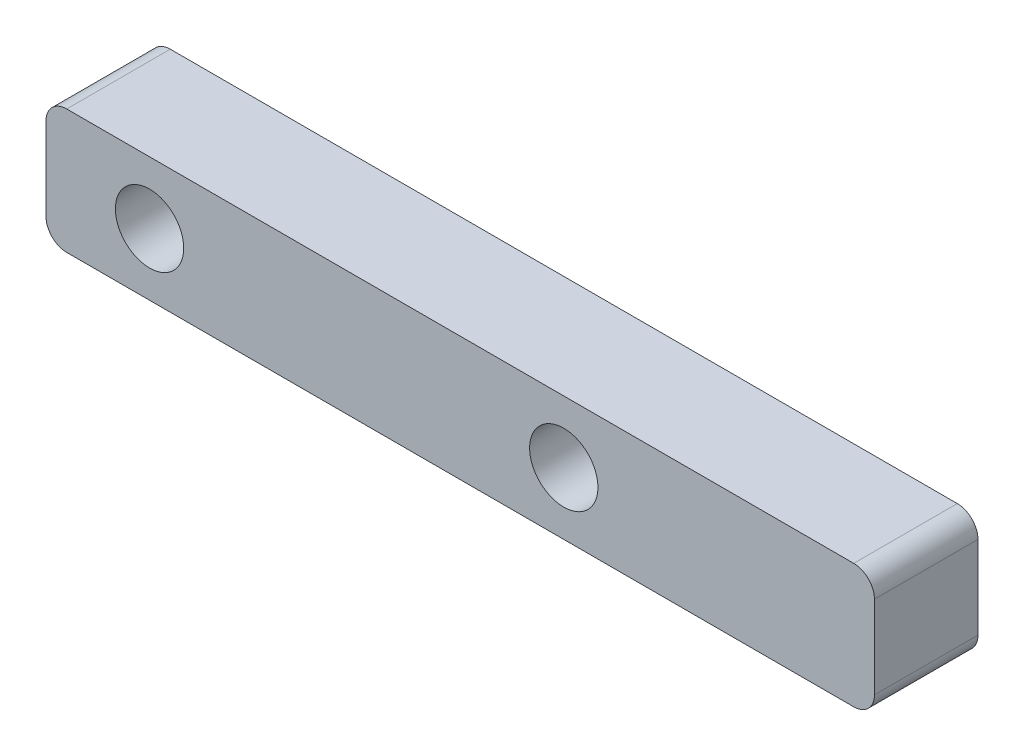
from build123d import *

# Parameters (mm, degrees)
SKETCH_1_W          = 40
SKETCH_1_H          = 6
EXTRUDE_1_DEPTH     = 5
SKETCH_2_R          = 1.65
CUT_EXTRUDE_1_DEPTH = 7
FILLET_1_R          = 1


with BuildPart() as part:
    # 草图1 → 凸台-拉伸1 (new body)
    with BuildSketch(Plane.XY):
        Rectangle(SKETCH_1_W, SKETCH_1_H)
    extrude(amount=EXTRUDE_1_DEPTH)

    # 草图2 → 切除-拉伸1 (cut)
    with BuildSketch(Plane.XY.offset(5)):
        with Locations((5, 0)):
            Circle(SKETCH_2_R)
        with Locations((-15, 0)):
            Circle(SKETCH_2_R)
    extrude(amount=-CUT_EXTRUDE_1_DEPTH, mode=Mode.SUBTRACT)

    # 圆角1
    fillet_1_edges = [part.edges().sort_by_distance(p)[0] for p in [
        (20, -3, 2.5),
        (-20, -3, 2.5),
        (-20, 3, 2.5),
        (20, 3, 2.5),
    ]]
    fillet(fillet_1_edges, radius=FILLET_1_R)


solid = part.part
